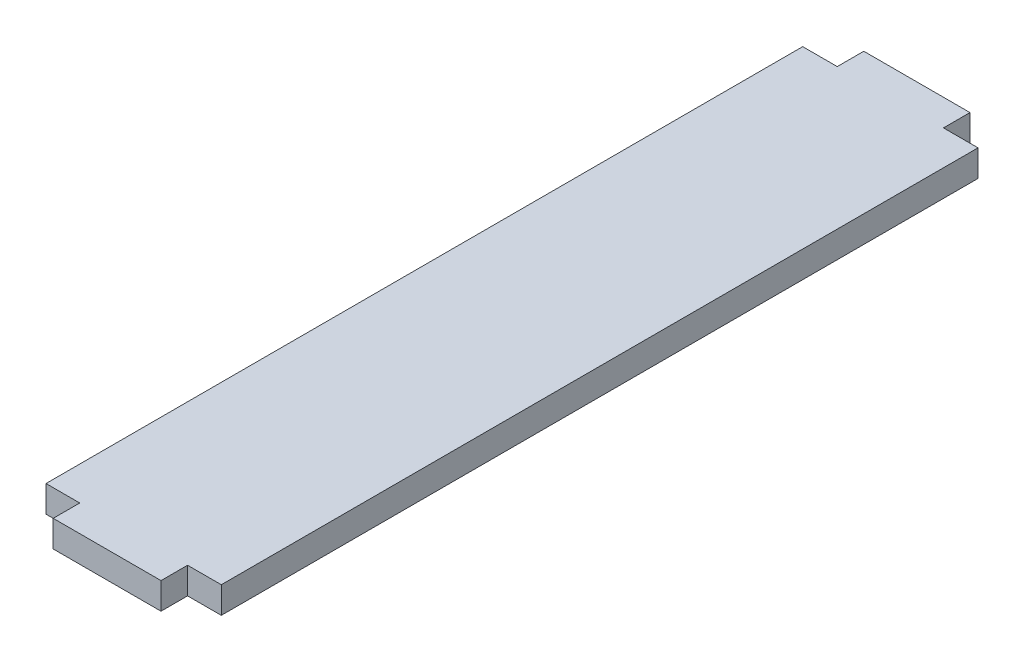
from build123d import *

# Parameters (mm, degrees)
SKETCH1_W           = 33.54
SKETCH1_H           = 144.78
BOSS_EXTRUDE1_DEPTH = 5.08
SKETCH2_W           = 20.32
SKETCH2_H           = 5.08
BOSS_EXTRUDE2_DEPTH = 5.08
SKETCH3_W           = 20.63
SKETCH3_H           = 5.08
BOSS_EXTRUDE3_DEPTH = 5.08


with BuildPart() as part:
    # Sketch1 → Boss-Extrude1 (new body)
    with BuildSketch(Plane(origin=(0, 0, 0), x_dir=(1, 0, 0), z_dir=(0, 1, 0))):
        with Locations((-16.77, 72.39)):
            Rectangle(SKETCH1_W, SKETCH1_H)
    extrude(amount=BOSS_EXTRUDE1_DEPTH)

    # Sketch2 → Boss-Extrude2 (add)
    with BuildSketch(Plane(origin=(0, 0, -144.78), x_dir=(-1, 0, 0), z_dir=(0, 0, -1))):
        with Locations((16.77, 2.54)):
            Rectangle(SKETCH2_W, SKETCH2_H)
    extrude(amount=BOSS_EXTRUDE2_DEPTH)

    # Sketch3 → Boss-Extrude3 (add)
    with BuildSketch(Plane.XY):
        with Locations((-16.77, 2.54)):
            Rectangle(SKETCH3_W, SKETCH3_H)
    extrude(amount=BOSS_EXTRUDE3_DEPTH)


solid = part.part
